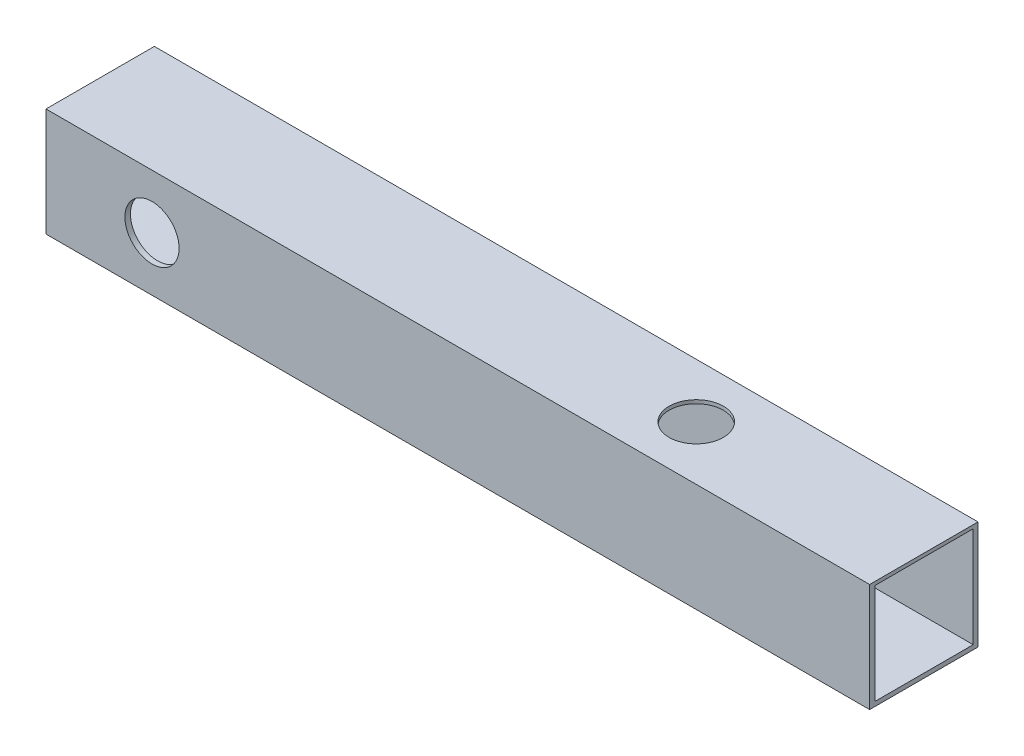
from build123d import *

# Parameters (mm, degrees)
SKETCH1_W           = 76
SKETCH1_H           = 10
BOSS_EXTRUDE1_DEPTH = 10
SKETCH2_W           = 9.046482833
SKETCH2_H           = 9.263922883
CUT_EXTRUDE1_DEPTH  = 77
SKETCH4_R           = 2.5
CUT_EXTRUDE2_DEPTH  = 76
SKETCH6_R           = 2.5
CUT_EXTRUDE3_DEPTH  = 76


with BuildPart() as part:
    # Sketch1 → Boss-Extrude1 (new body)
    with BuildSketch(Plane(origin=(0, 0, 0), x_dir=(1, 0, 0), z_dir=(0, 1, 0))):
        Rectangle(SKETCH1_W, SKETCH1_H)
    extrude(amount=BOSS_EXTRUDE1_DEPTH)

    # Sketch2 → Cut-Extrude1 (cut, through all)
    with BuildSketch(Plane.ZY.offset(38)):
        with Locations((-0.032492444, 5.042490422)):
            Rectangle(SKETCH2_W, SKETCH2_H)
    extrude(amount=-CUT_EXTRUDE1_DEPTH, mode=Mode.SUBTRACT)

    # Sketch4 → Cut-Extrude2 (cut)
    with BuildSketch(Plane.XY.offset(5)):
        with Locations((-28.218728934, 5)):
            Circle(SKETCH4_R)
    extrude(amount=-CUT_EXTRUDE2_DEPTH, mode=Mode.SUBTRACT)

    # Sketch6 → Cut-Extrude3 (cut)
    with BuildSketch(Plane(origin=(0, 10, 0), x_dir=(1, 0, 0), z_dir=(0, 1, 0))):
        with Locations((17, 0)):
            Circle(SKETCH6_R)
    extrude(amount=-CUT_EXTRUDE3_DEPTH, mode=Mode.SUBTRACT)


solid = part.part
